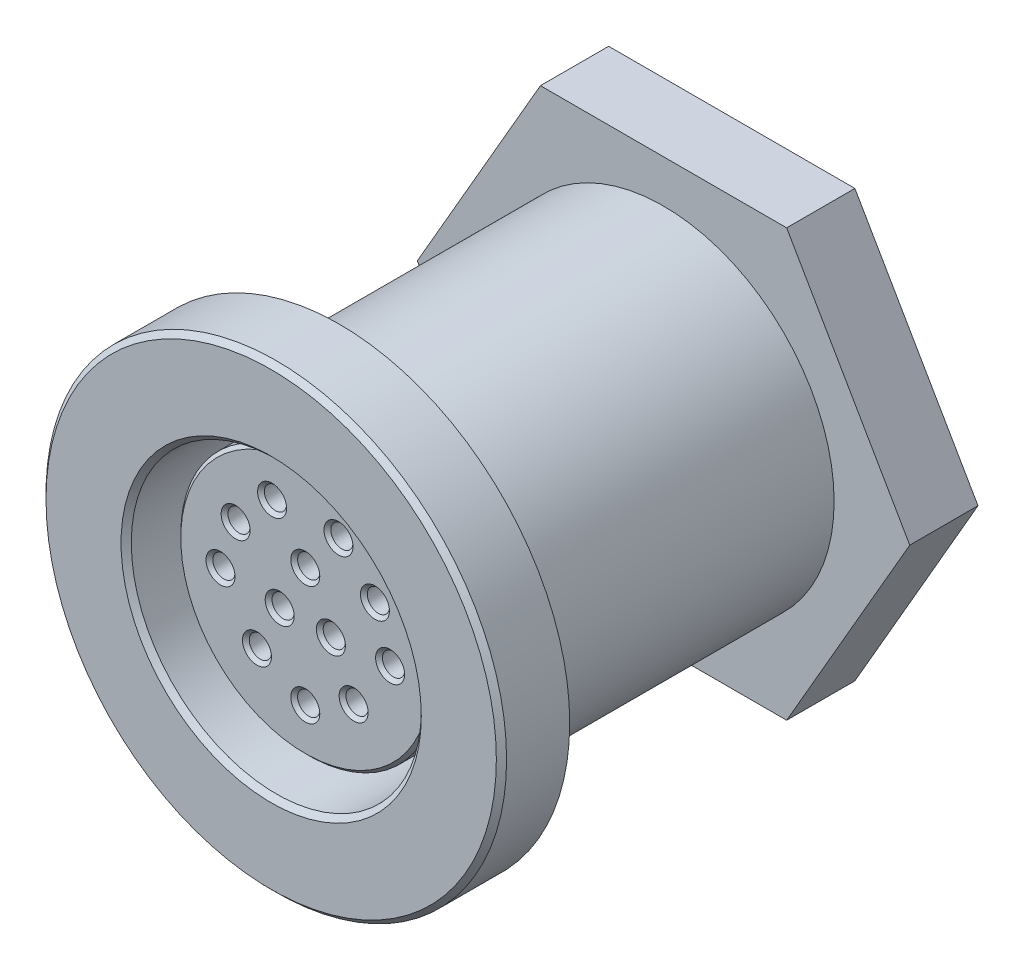
from build123d import *

# Parameters (mm, degrees)
SKETCH1_R          = 13.5
EXTRUDE1_DEPTH     = 4
SKETCH3_R          = 10
EXTRUDE3_DEPTH     = 25
SKETCH7_R          = 8.5
CUT_EXTRUDE5_DEPTH = 16
SKETCH4_R          = 7.5
EXTRUDE4_DEPTH     = 14
CHAMFER1_SIZE      = 0.2
CHAMFER3_SIZE      = 0.3
SKETCH5_R          = 12
SKETCH5_R_2        = 10
CUT_EXTRUDE1_DEPTH = 1.5
SKETCH8_R          = 8
CUT_EXTRUDE6_DEPTH = 2
CHAMFER5_SIZE      = 1
SKETCH6_R          = 0.65
CUT_EXTRUDE2_DEPTH = 5
CHAMFER6_SIZE      = 0.2
EXTRUDE5_DEPTH     = 4


with BuildPart() as part:
    # Sketch1 → Extrude1 (new body)
    with BuildSketch(Plane.XY):
        Circle(SKETCH1_R)
    extrude(amount=EXTRUDE1_DEPTH)

    # Sketch3 → Extrude3 (add)
    with BuildSketch(Plane(origin=(0, 0, 0), x_dir=(-1, 0, 0), z_dir=(0, 0, -1))):
        Circle(SKETCH3_R)
    extrude(amount=EXTRUDE3_DEPTH)

    # Sketch7 → Cut-Extrude5 (cut)
    with BuildSketch(Plane.XY.offset(4)):
        Circle(SKETCH7_R)
    extrude(amount=-CUT_EXTRUDE5_DEPTH, mode=Mode.SUBTRACT)

    # Sketch4 → Extrude4 (add)
    with BuildSketch(Plane.XY.offset(-12)):
        Circle(SKETCH4_R)
    extrude(amount=EXTRUDE4_DEPTH)

    # Chamfer1
    chamfer1_edges = [part.edges().sort_by_distance(p)[0] for p in [
        (-7.5, 0, 2),
    ]]
    chamfer(chamfer1_edges, length=CHAMFER1_SIZE)

    # Chamfer3
    chamfer3_edges = [part.edges().sort_by_distance(p)[0] for p in [
        (-8.5, 0, 4),
        (-13.5, 0, 4),
    ]]
    chamfer(chamfer3_edges, length=CHAMFER3_SIZE)

    # Sketch5 → Cut-Extrude1 (cut)
    with BuildSketch(Plane(origin=(0, 0, 0), x_dir=(-1, 0, 0), z_dir=(0, 0, -1))):
        Circle(SKETCH5_R)
        Circle(SKETCH5_R_2, mode=Mode.SUBTRACT)
    extrude(amount=-CUT_EXTRUDE1_DEPTH, mode=Mode.SUBTRACT)

    # Sketch8 → Cut-Extrude6 (cut)
    with BuildSketch(Plane(origin=(0, 0, -25), x_dir=(-1, 0, 0), z_dir=(0, 0, -1))):
        Circle(SKETCH8_R)
    extrude(amount=-CUT_EXTRUDE6_DEPTH, mode=Mode.SUBTRACT)

    # Chamfer5
    chamfer5_edges = [part.edges().sort_by_distance(p)[0] for p in [
        (10, 0, -25),
    ]]
    chamfer(chamfer5_edges, length=CHAMFER5_SIZE)

    # Sketch6 → Cut-Extrude2 (cut)
    with BuildSketch(Plane.XY.offset(2)):
        with Locations((1.500332219, -0.655252352)):
            Circle(SKETCH6_R)
        with Locations((0, 2.126873458)):
            Circle(SKETCH6_R)
        with Locations((0, -4.848601397)):
            Circle(SKETCH6_R)
        with Locations((2.83413915, -3.376897165)):
            Circle(SKETCH6_R)
        with Locations((1.947084544, 4.606594287)):
            Circle(SKETCH6_R)
        with Locations((4.971134337, -0.373007704)):
            Circle(SKETCH6_R)
        with Locations((-4.084079731, 2.409118105)):
            Circle(SKETCH6_R)
        with Locations((-4.971134337, -0.373007704)):
            Circle(SKETCH6_R)
        with Locations((-1.947084544, 4.606594287)):
            Circle(SKETCH6_R)
        with Locations((-2.83413915, -3.376897165)):
            Circle(SKETCH6_R)
        with Locations((-1.500332219, -0.655252352)):
            Circle(SKETCH6_R)
        with Locations((4.084079731, 2.409118105)):
            Circle(SKETCH6_R)
    extrude(amount=-CUT_EXTRUDE2_DEPTH, mode=Mode.SUBTRACT)

    # Chamfer6
    chamfer6_edges = [part.edges().sort_by_distance(p)[0] for p in [
        (0.850332219, -0.655252352, 2),
        (-0.65, 2.126873458, 2),
        (-0.65, -4.848601397, 2),
        (1.297084544, 4.606594287, 2),
        (2.18413915, -3.376897165, 2),
        (4.321134337, -0.373007704, 2),
        (-4.734079731, 2.409118105, 2),
        (-5.621134337, -0.373007704, 2),
        (-2.597084544, 4.606594287, 2),
        (-3.48413915, -3.376897165, 2),
        (-2.150332219, -0.655252352, 2),
        (3.434079731, 2.409118105, 2),
    ]]
    chamfer(chamfer6_edges, length=CHAMFER6_SIZE)

    # Sketch9 → Extrude5 (add)
    with BuildSketch(Plane(origin=(0, 0, -23), x_dir=(-1, 0, 0), z_dir=(0, 0, -1))):
        Polygon((-7.216878365, 12.5), (7.216878365, 12.5), (14.43375673, 0), (7.216878365, -12.5), (-7.216878365, -12.5), (-14.43375673, 0), align=None)
    extrude(amount=-EXTRUDE5_DEPTH)


solid = part.part
